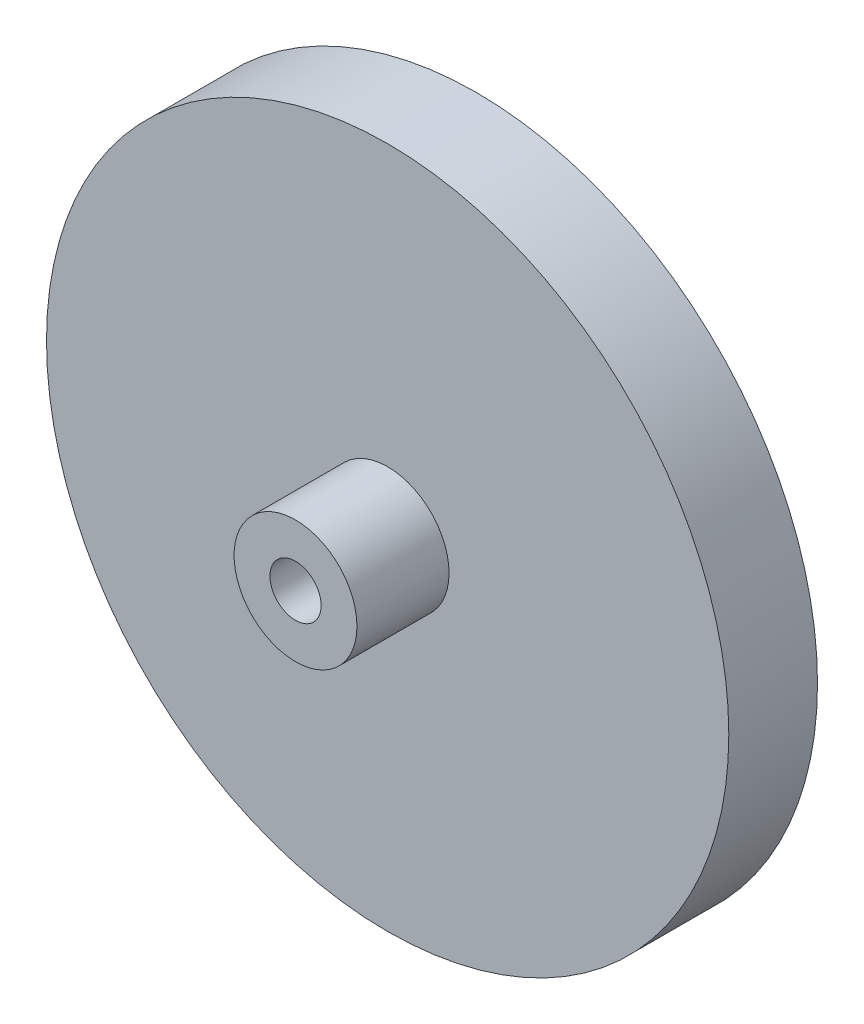
from build123d import *

# Parameters (mm, degrees)
SKETCH1_R               = 25
BOSS_EXTRUDE2_DEPTH     = 3.25
SKETCH2_R               = 4.5
BOSS_EXTRUDE3_DEPTH     = 10
SKETCH3_R               = 4.5
BOSS_EXTRUDE4_DEPTH     = 5
SKETCH4_R               = 3.1
CUT_EXTRUDE1_DEPTH      = 2.5
SKETCH6_R               = 1.875
CUT_EXTRUDE2_DEPTH      = 1
CUT_EXTRUDE2_DEPTH_BACK = 19.25


with BuildPart() as part:
    # Sketch1 → Boss-Extrude2 (new body, symmetric)
    with BuildSketch(Plane.XY):
        Circle(SKETCH1_R)
    extrude(amount=BOSS_EXTRUDE2_DEPTH, both=True)

    # Sketch2 → Boss-Extrude3 (add)
    with BuildSketch(Plane.XY):
        Circle(SKETCH2_R)
    extrude(amount=BOSS_EXTRUDE3_DEPTH)

    # Sketch3 → Boss-Extrude4 (add)
    with BuildSketch(Plane(origin=(0, 0, -3.25), x_dir=(-1, 0, 0), z_dir=(0, 0, -1))):
        Circle(SKETCH3_R)
    extrude(amount=BOSS_EXTRUDE4_DEPTH)

    # Sketch4 → Cut-Extrude1 (cut)
    with BuildSketch(Plane(origin=(0, 0, -8.25), x_dir=(-1, 0, 0), z_dir=(0, 0, -1))):
        Circle(SKETCH4_R)
    extrude(amount=-CUT_EXTRUDE1_DEPTH, mode=Mode.SUBTRACT)

    # Sketch6 → Cut-Extrude2 (cut, two sides)
    with BuildSketch(Plane.XY.offset(10)) as cut_extrude2_sk:
        Circle(SKETCH6_R)
    extrude(amount=CUT_EXTRUDE2_DEPTH, mode=Mode.SUBTRACT)
    extrude(cut_extrude2_sk.sketch, amount=-CUT_EXTRUDE2_DEPTH_BACK, mode=Mode.SUBTRACT)


solid = part.part
